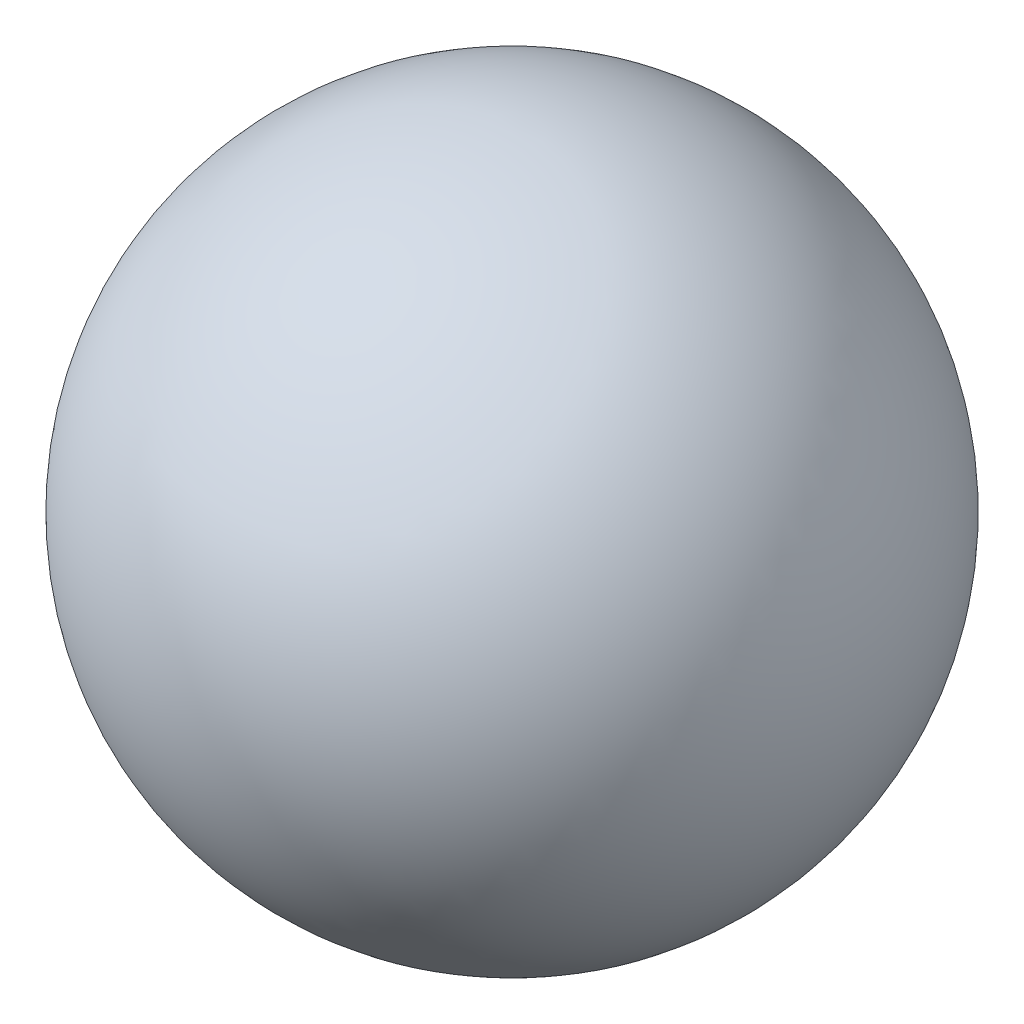
from build123d import *


with BuildPart() as part:
    # Esquisse1 → Révolution1 (revolve)
    with BuildSketch(Plane.XY):
        with BuildLine():
            Line((10.274369758, 21.631113007), (10.274369758, -18.368886993))
            ThreePointArc((10.274369758, -18.368886993), (30.274369758, 1.631113007), (10.274369758, 21.631113007))
        make_face()
    revolve(axis=Axis((10.274369758, 1.631113007, 0), (0, -1, 0)))


solid = part.part
